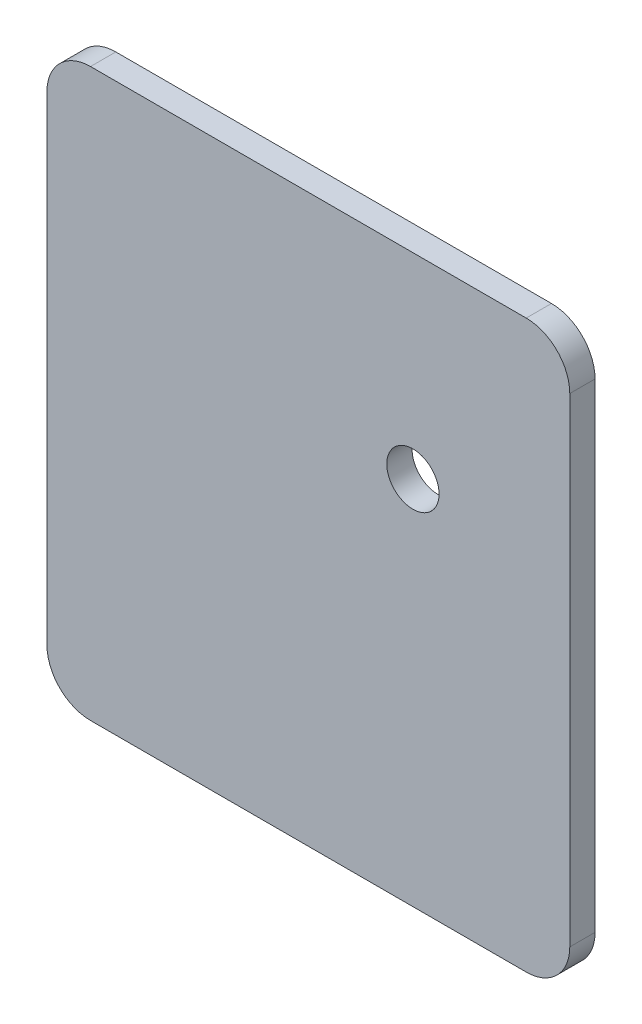
from build123d import *

# Parameters (mm, degrees)
CROQUIS1_W              = 60
CROQUIS1_H              = 65
CROQUIS1_R              = 3
SALIENTE_EXTRUIR1_DEPTH = 2.9
REDONDEO2_R             = 5
REDONDEO3_R             = 5
REDONDEO4_R             = 5
REDONDEO5_R             = 5


with BuildPart() as part:
    # Croquis1 → Saliente-Extruir1 (new body)
    with BuildSketch(Plane.XY):
        with Locations((30, 32.5)):
            Rectangle(CROQUIS1_W, CROQUIS1_H)
        with Locations((42, 42.5)):
            Circle(CROQUIS1_R, mode=Mode.SUBTRACT)
    extrude(amount=-SALIENTE_EXTRUIR1_DEPTH)

    # Redondeo2
    redondeo2_edges = [part.edges().sort_by_distance(p)[0] for p in [
        (0, 65, -1.45),
    ]]
    fillet(redondeo2_edges, radius=REDONDEO2_R)

    # Redondeo3
    redondeo3_edges = [part.edges().sort_by_distance(p)[0] for p in [
        (60, 65, -1.45),
    ]]
    fillet(redondeo3_edges, radius=REDONDEO3_R)

    # Redondeo4
    redondeo4_edges = [part.edges().sort_by_distance(p)[0] for p in [
        (60, 0, -1.45),
    ]]
    fillet(redondeo4_edges, radius=REDONDEO4_R)

    # Redondeo5
    redondeo5_edges = [part.edges().sort_by_distance(p)[0] for p in [
        (0, 0, -1.45),
    ]]
    fillet(redondeo5_edges, radius=REDONDEO5_R)


solid = part.part
